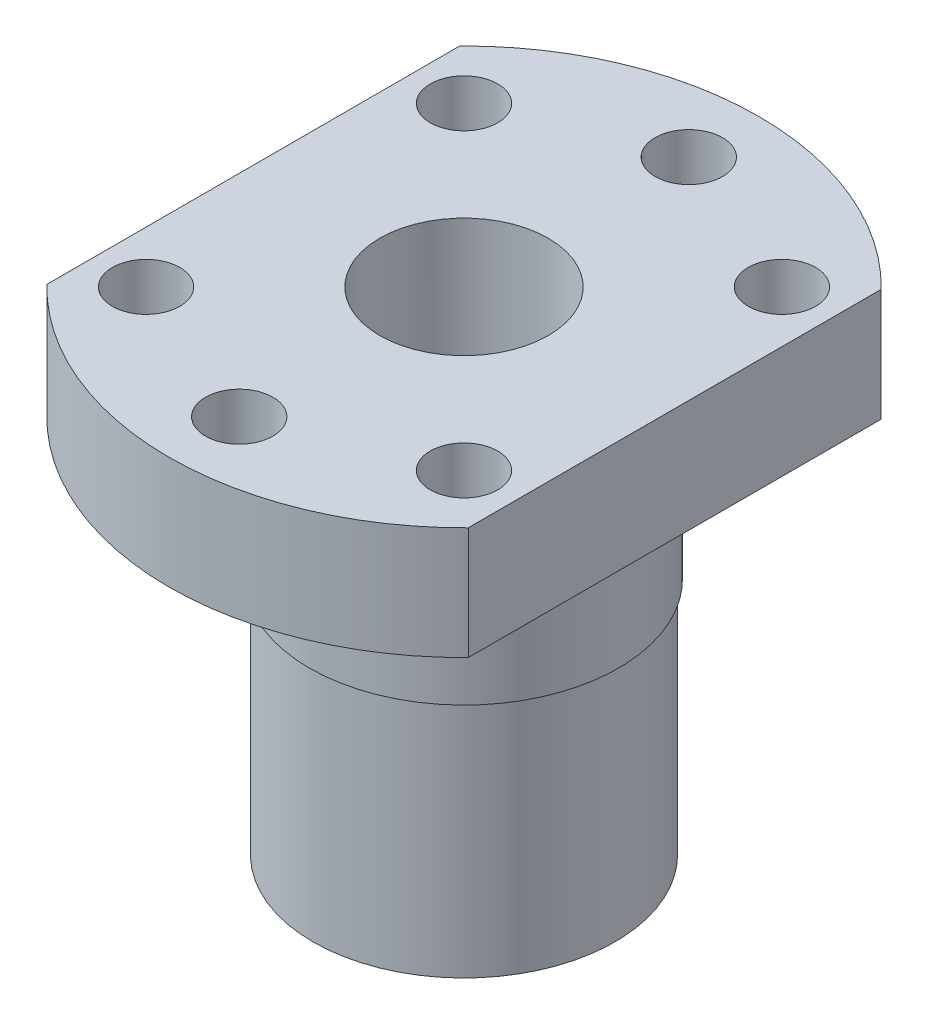
from build123d import *

# Parameters (mm, degrees)
SKETCH1_R           = 6
SKETCH1_R_2         = 2.4
BOSS_EXTRUDE1_DEPTH = 8
SKETCH2_R           = 11
SKETCH2_R_2         = 6
BOSS_EXTRUDE2_DEPTH = 10
SKETCH3_R           = 10.75
SKETCH3_R_2         = 6
BOSS_EXTRUDE3_DEPTH = 17


with BuildPart() as part:
    # Sketch1 → Boss-Extrude1 (new body)
    with BuildSketch(Plane(origin=(0, 0, 0), x_dir=(1, 0, 0), z_dir=(0, 1, 0))):
        with BuildLine():
            Line((-15, 14.696938457), (-15, -14.696938457))
            ThreePointArc((-15, -14.696938457), (0, -21), (15, -14.696938457))
            Line((15, -14.696938457), (15, 14.696938457))
            ThreePointArc((15, 14.696938457), (0, 21), (-15, 14.696938457))
        make_face()
        Circle(SKETCH1_R, mode=Mode.SUBTRACT)
        with Locations((0, 16)):
            Circle(SKETCH1_R_2, mode=Mode.SUBTRACT)
        with Locations((11.313708499, 11.313708499)):
            Circle(SKETCH1_R_2, mode=Mode.SUBTRACT)
        with Locations((-11.313708499, 11.313708499)):
            Circle(SKETCH1_R_2, mode=Mode.SUBTRACT)
        with Locations((11.313708499, -11.313708499)):
            Circle(SKETCH1_R_2, mode=Mode.SUBTRACT)
        with Locations((0, -16)):
            Circle(SKETCH1_R_2, mode=Mode.SUBTRACT)
        with Locations((-11.313708499, -11.313708499)):
            Circle(SKETCH1_R_2, mode=Mode.SUBTRACT)
    extrude(amount=BOSS_EXTRUDE1_DEPTH)

    # Sketch2 → Boss-Extrude2 (add)
    with BuildSketch(Plane.XZ):
        Circle(SKETCH2_R)
        Circle(SKETCH2_R_2, mode=Mode.SUBTRACT)
    extrude(amount=BOSS_EXTRUDE2_DEPTH)

    # Sketch3 → Boss-Extrude3 (add)
    with BuildSketch(Plane.XZ.offset(10)):
        Circle(SKETCH3_R)
        Circle(SKETCH3_R_2, mode=Mode.SUBTRACT)
    extrude(amount=BOSS_EXTRUDE3_DEPTH)


solid = part.part
